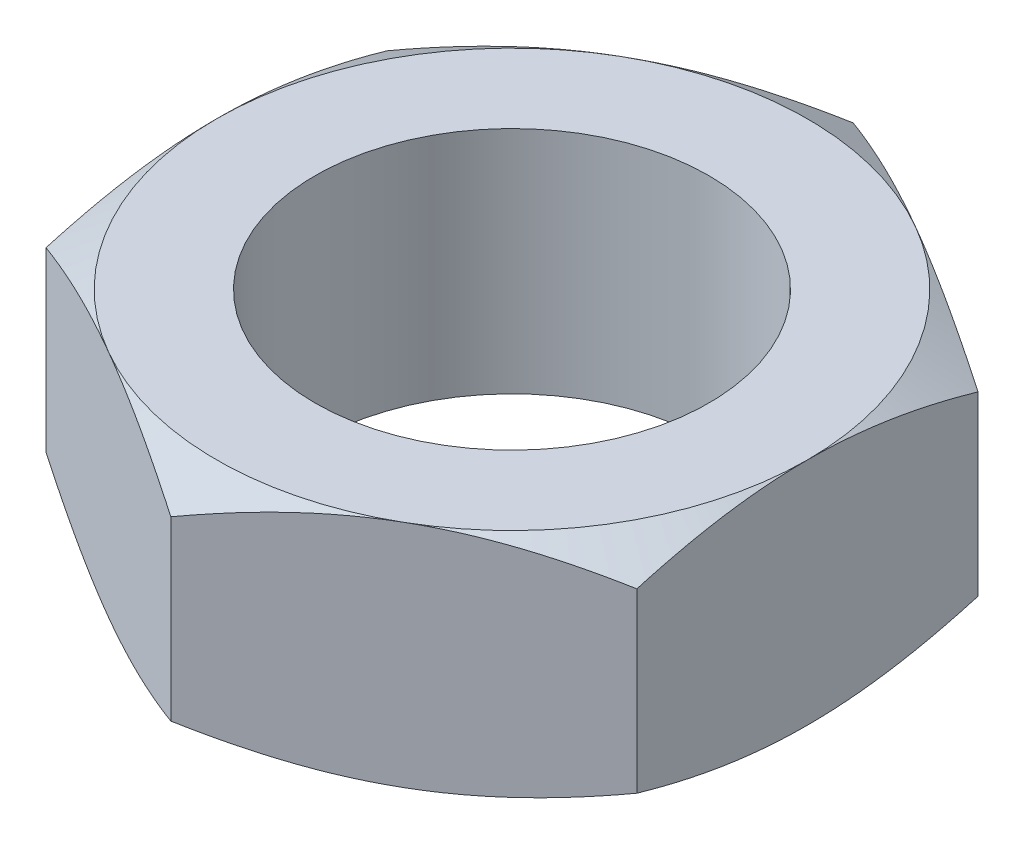
from build123d import *

# Parameters (mm, degrees)
SKETCH1_R               = 4.7625
BOSS_EXTRUDE1_DEPTH     = 2.778125
SKETCH5_OUTSIDE_W       = 66.676
SKETCH5_OUTSIDE_H       = 68.886
SKETCH5_OUTSIDE_R       = 7.14375
CUT_EXTRUDE2_DEPTH      = 13.245378593
CUT_EXTRUDE2_DRAFT      = -60
MIRROR1_COPY_1_SKETCH_W = 66.676
MIRROR1_COPY_1_SKETCH_H = 68.886
MIRROR1_COPY_1_SKETCH_R = 7.14375
MIRROR1_COPY_1_DEPTH    = 13.245378593
MIRROR1_COPY_1_DRAFT    = -60


with BuildPart() as part:
    # Sketch1 → Boss-Extrude1 (new, symmetric)
    with BuildSketch(Plane(origin=(0, 0, 0), x_dir=(1, 0, 0), z_dir=(0, 1, 0))):
        Polygon((-7.14375, 4.124445986), (-7.14375, -4.124445986), (0, -8.248891971), (7.14375, -4.124445986), (7.14375, 4.124445986), (0, 8.248891971), align=None)
        Circle(SKETCH1_R, mode=Mode.SUBTRACT)
    extrude(amount=BOSS_EXTRUDE1_DEPTH, both=True)


with BuildPart() as cut_extrude2_tool:
    # Sketch5 outside → Cut-Extrude2 (with draft: the straight prism first)
    with BuildSketch(Plane(origin=(0, 2.778125, 0), x_dir=(1, 0, 0), z_dir=(0, 1, 0))):
        Rectangle(SKETCH5_OUTSIDE_W, SKETCH5_OUTSIDE_H)
        Circle(SKETCH5_OUTSIDE_R, mode=Mode.SUBTRACT)
    extrude(amount=-CUT_EXTRUDE2_DEPTH)
    # Cut-Extrude2: the draft: its side faces are tilted about the plane it starts from
    cut_extrude2_sides = [cut_extrude2_tool.faces().sort_by_distance(p)[0] for p in [
        (0, -3.844564296, 34.443),
        (33.338, -3.844564296, 0),
        (0, -3.844564296, -34.443),
        (-33.338, -3.844564296, 0),
        (-7.14375, -3.844564296, 0),
    ]]
    draft(cut_extrude2_sides, Plane(origin=(0, 2.778125, 0), x_dir=(1, 0, 0), z_dir=(0, 1, 0)), CUT_EXTRUDE2_DRAFT)


with BuildPart() as part_1:
    add(part.part)

    # Cut-Extrude2: cut by cut_extrude2_tool
    add(cut_extrude2_tool.part, mode=Mode.SUBTRACT)


with BuildPart() as mirror1_copy_1_tool:
    # Mirror1 copy 1 sketch → Mirror1 copy 1 (with draft: the straight prism first)
    with BuildSketch(Plane.XZ.offset(2.778125)):
        Rectangle(MIRROR1_COPY_1_SKETCH_W, MIRROR1_COPY_1_SKETCH_H)
        Circle(MIRROR1_COPY_1_SKETCH_R, mode=Mode.SUBTRACT)
    extrude(amount=-MIRROR1_COPY_1_DEPTH)
    # Mirror1 copy 1: the draft: its side faces are tilted about the plane it starts from
    mirror1_copy_1_sides = [mirror1_copy_1_tool.faces().sort_by_distance(p)[0] for p in [
        (0, 3.844564296, 34.443),
        (33.338, 3.844564296, 0),
        (0, 3.844564296, -34.443),
        (-33.338, 3.844564296, 0),
        (-7.14375, 3.844564296, 0),
    ]]
    draft(mirror1_copy_1_sides, Plane.XZ.offset(2.778125), MIRROR1_COPY_1_DRAFT)


with BuildPart() as part_2:
    add(part_1.part)

    # Mirror1 copy 1: cut by mirror1_copy_1_tool
    add(mirror1_copy_1_tool.part, mode=Mode.SUBTRACT)


solid = part_2.part
